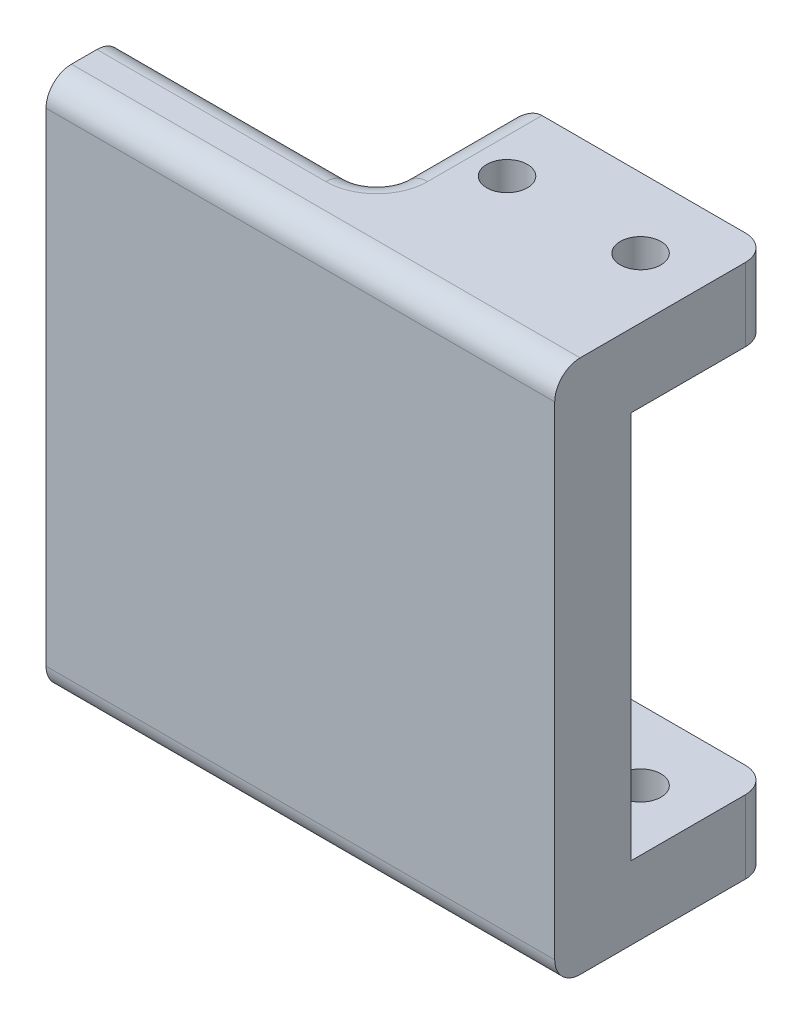
from build123d import *

# Parameters (mm, degrees)
SKETCH1_W           = 20
SKETCH1_H           = 11
SKETCH1_R           = 1.6
BOSS_EXTRUDE1_DEPTH = 42
SKETCH2_W           = 20
SKETCH2_H           = 30.5
CUT_EXTRUDE1_DEPTH  = 11
FILLET1_R           = 2


with BuildPart() as part:
    # Sketch1 → Boss-Extrude1 (new body)
    with BuildSketch(Plane(origin=(0, 0, 0), x_dir=(1, 0, 0), z_dir=(0, 1, 0))):
        Rectangle(SKETCH1_W, SKETCH1_H)
        with Locations((5.25, 0)):
            Circle(SKETCH1_R, mode=Mode.SUBTRACT)
        with Locations((-5.25, 0)):
            Circle(SKETCH1_R, mode=Mode.SUBTRACT)
        Polygon((10, -5.5), (-10, -5.5), (-30, -5.5), (-30, -11.5), (10, -11.5), align=None)
    extrude(amount=BOSS_EXTRUDE1_DEPTH)

    # Sketch2 → Cut-Extrude1 (cut)
    with BuildSketch(Plane(origin=(0, 0, -5.5), x_dir=(-1, 0, 0), z_dir=(0, 0, -1))):
        with Locations((0, 21)):
            Rectangle(SKETCH2_W, SKETCH2_H)
    extrude(amount=-CUT_EXTRUDE1_DEPTH, mode=Mode.SUBTRACT)

    # Fillet1
    fillet1_edges = [part.edges().sort_by_distance(p)[0] for p in [
        (-10, 0, 11.5),
        (-20, 0, 5.5),
        (-10, 0, 0),
        (-10, 39.125, 5.5),
        (-10, 39.125, -5.5),
        (10, 39.125, -5.5),
        (-10, 42, 0),
        (-10, 2.875, 5.5),
        (-10, 2.875, -5.5),
        (10, 2.875, -5.5),
        (-20, 42, 5.5),
        (-10, 42, 11.5),
    ]]
    fillet(fillet1_edges, radius=FILLET1_R)


solid = part.part
